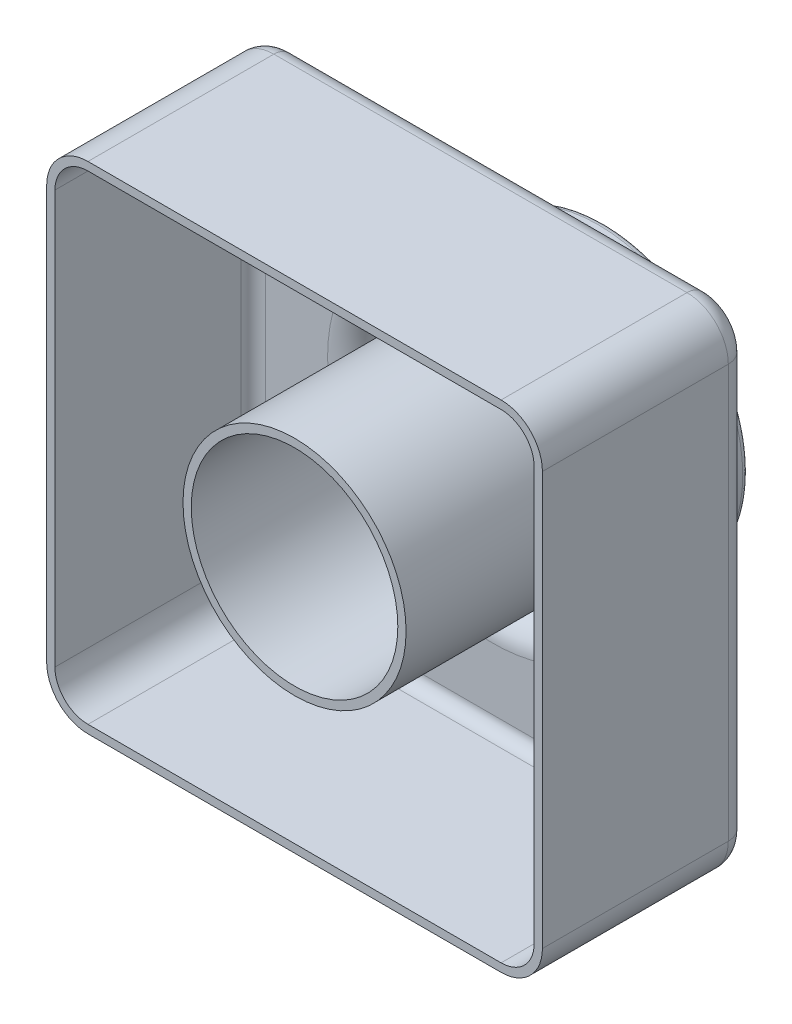
from build123d import *

# Parameters (mm, degrees)
SKETCH2_W           = 120
SKETCH2_H           = 120
BOSS_EXTRUDE2_DEPTH = 50
SKETCH4_R           = 35
BOSS_EXTRUDE3_DEPTH = 25
SKETCH5_R           = 25
CUT_EXTRUDE1_DEPTH  = 186.539753153
FILLET1_R           = 10
FILLET2_R           = 1.5
FILLET3_R           = 5
SHELL2_T            = -2


with BuildPart() as part:
    # Sketch2 → Boss-Extrude2 (new body)
    with BuildSketch(Plane.XY):
        with Locations((60, 60)):
            Rectangle(SKETCH2_W, SKETCH2_H)
    extrude(amount=BOSS_EXTRUDE2_DEPTH)

    # Sketch4 → Boss-Extrude3 (add)
    with BuildSketch(Plane(origin=(0, 0, 0), x_dir=(-1, 0, 0), z_dir=(0, 0, -1))):
        with Locations((-60, 60)):
            Circle(SKETCH4_R)
    extrude(amount=BOSS_EXTRUDE3_DEPTH)

    # Sketch5 → Cut-Extrude1 (cut, through all)
    with BuildSketch(Plane(origin=(0, 0, -25), x_dir=(-1, 0, 0), z_dir=(0, 0, -1))):
        with Locations((-60, 60)):
            Circle(SKETCH5_R)
    extrude(amount=-CUT_EXTRUDE1_DEPTH, mode=Mode.SUBTRACT)

    # Fillet1
    fillet1_edges = [part.edges().sort_by_distance(p)[0] for p in [
        (0, 120, 25),
        (120, 120, 25),
        (120, 0, 25),
        (0, 0, 25),
    ]]
    fillet(fillet1_edges, radius=FILLET1_R)

    # Fillet2
    fillet2_edges = [part.edges().sort_by_distance(p)[0] for p in [
        (95, 60, -25),
        (85, 60, -25),
    ]]
    fillet(fillet2_edges, radius=FILLET2_R)

    # Fillet3
    fillet3_edges = [part.edges().sort_by_distance(p)[0] for p in [
        (95, 60, 0),
        (60, 0, 0),
        (0, 60, 0),
        (60, 120, 0),
        (120, 60, 0),
        (2.928932188, 117.071067812, 0),
        (117.071067812, 117.071067812, 0),
        (117.071067812, 2.928932188, 0),
        (2.928932188, 2.928932188, 0),
    ]]
    fillet(fillet3_edges, radius=FILLET3_R)

    # Shell2
    shell2_openings = [part.faces().sort_by_distance(p)[0] for p in [
        (60, 1.697056275, 50),
    ]]
    offset(amount=SHELL2_T, openings=shell2_openings, kind=Kind.INTERSECTION)


solid = part.part
